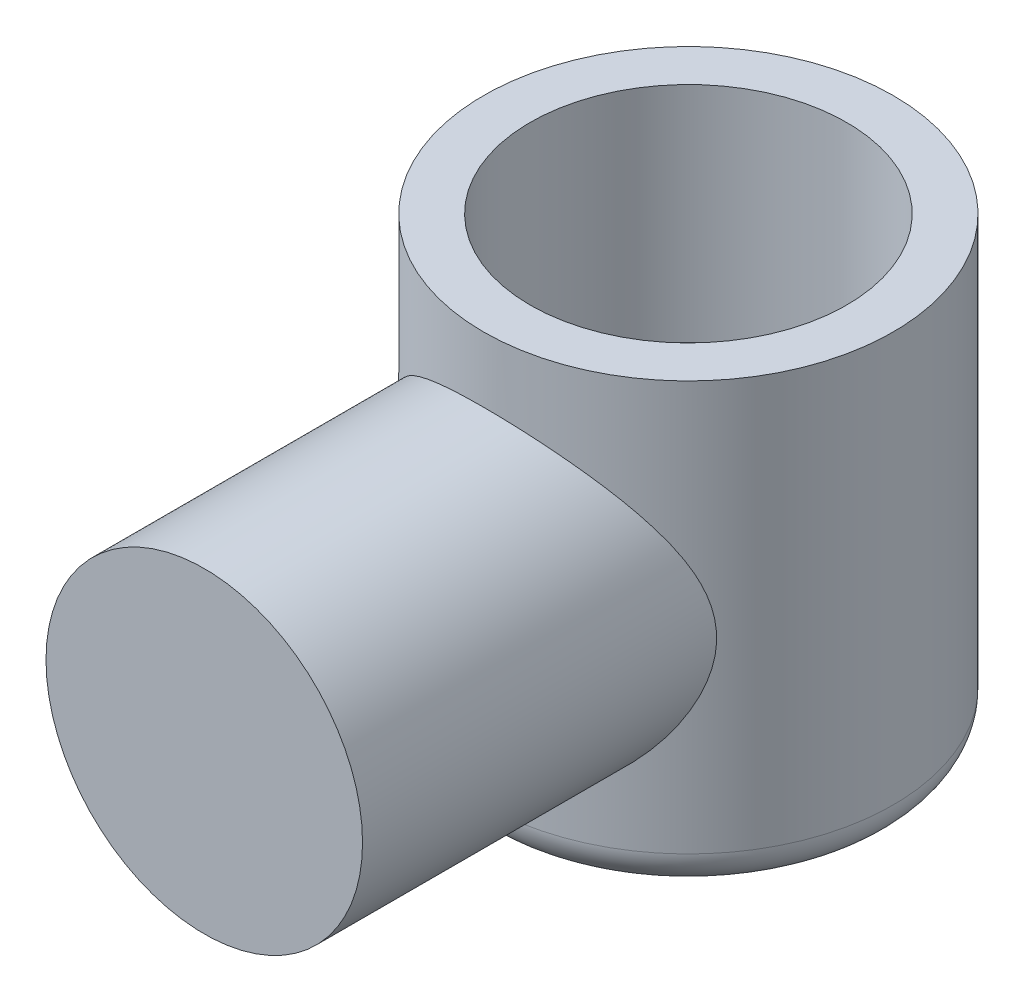
from build123d import *

# Parameters (mm, degrees)
SKETCH1_R           = 55
BOSS_EXTRUDE1_DEPTH = 60
SKETCH2_R           = 42.5
BOSS_EXTRUDE2_DEPTH = 130
FILLET2_R           = 10
SKETCH3_R           = 42.5
CUT_EXTRUDE1_DEPTH  = 110


with BuildPart() as part:
    # Sketch1 → Boss-Extrude1 (new body, symmetric)
    with BuildSketch(Plane(origin=(0, 0, 0), x_dir=(1, 0, 0), z_dir=(0, 1, 0))):
        Circle(SKETCH1_R)
    extrude(amount=BOSS_EXTRUDE1_DEPTH, both=True)

    # Sketch2 → Boss-Extrude2 (add)
    with BuildSketch(Plane.XY):
        Circle(SKETCH2_R)
    extrude(amount=BOSS_EXTRUDE2_DEPTH)

    # Fillet2
    fillet2_edges = [part.edges().sort_by_distance(p)[0] for p in [
        (-55, -60, 0),
    ]]
    fillet(fillet2_edges, radius=FILLET2_R)

    # Sketch3 → Cut-Extrude1 (cut)
    with BuildSketch(Plane(origin=(0, 0, 0), x_dir=(1, 0, 0), z_dir=(0, 1, 0))):
        Circle(SKETCH3_R)
    extrude(amount=CUT_EXTRUDE1_DEPTH, mode=Mode.SUBTRACT)


solid = part.part
